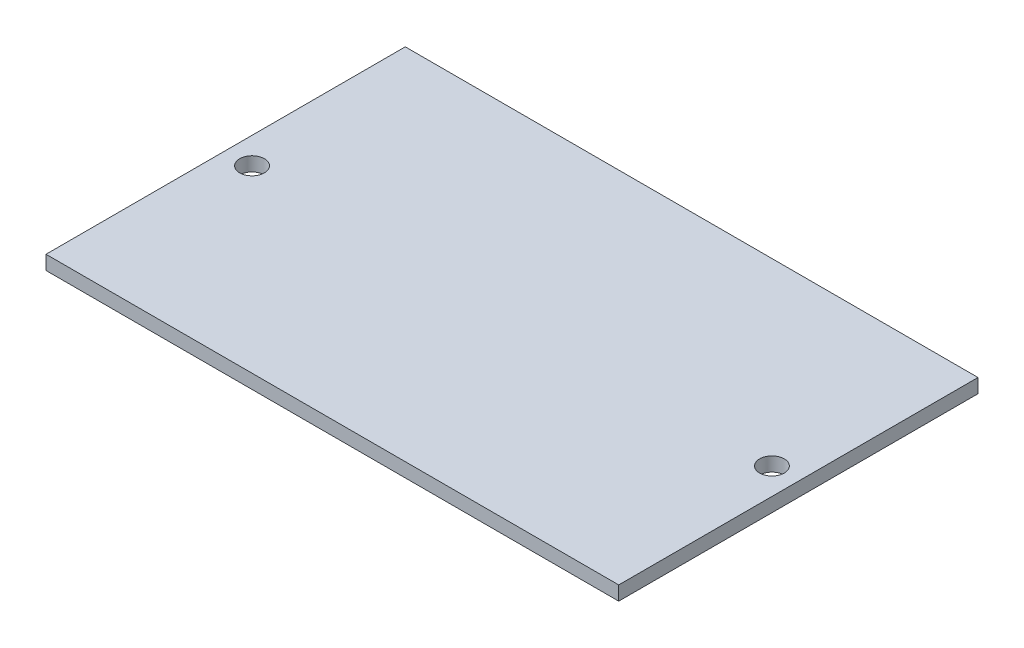
from build123d import *

# Parameters (mm, degrees)
SKETCH1_W           = 81.3
SKETCH1_H           = 51
BOSS_EXTRUDE1_DEPTH = 2
SKETCH2_R           = 1.75
CUT_EXTRUDE1_DEPTH  = 2


with BuildPart() as part:
    # Sketch1 → Boss-Extrude1 (new body)
    with BuildSketch(Plane(origin=(0, 0, 0), x_dir=(1, 0, 0), z_dir=(0, 1, 0))):
        Rectangle(SKETCH1_W, SKETCH1_H)
    extrude(amount=BOSS_EXTRUDE1_DEPTH)

    # Sketch2 → Cut-Extrude1 (cut)
    with BuildSketch(Plane(origin=(0, 2, 0), x_dir=(1, 0, 0), z_dir=(0, 1, 0))):
        with Locations((-36.9, 0)):
            Circle(SKETCH2_R)
        with Locations((36.9, 0)):
            Circle(SKETCH2_R)
    extrude(amount=-CUT_EXTRUDE1_DEPTH, mode=Mode.SUBTRACT)


solid = part.part
